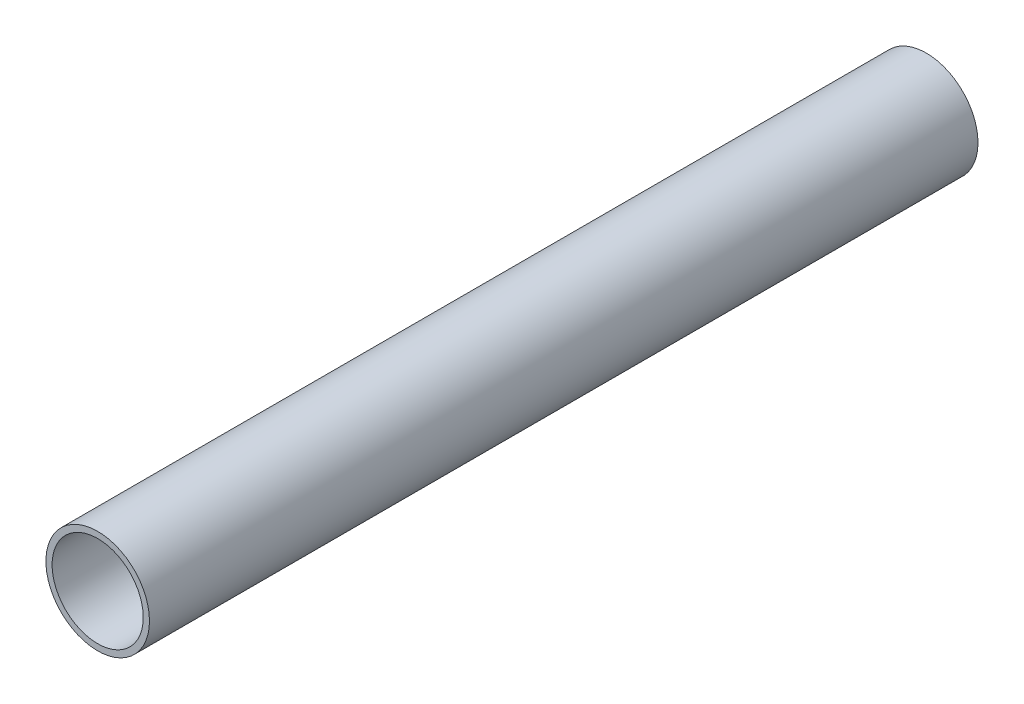
from build123d import *

# Parameters (mm, degrees)
SKETCH1_R           = 12.5
SKETCH1_R_2         = 11
BOSS_EXTRUDE1_DEPTH = 200


with BuildPart() as part:
    # Sketch1 → Boss-Extrude1 (new body)
    with BuildSketch(Plane.XY):
        Circle(SKETCH1_R)
        Circle(SKETCH1_R_2, mode=Mode.SUBTRACT)
    extrude(amount=BOSS_EXTRUDE1_DEPTH)


solid = part.part
